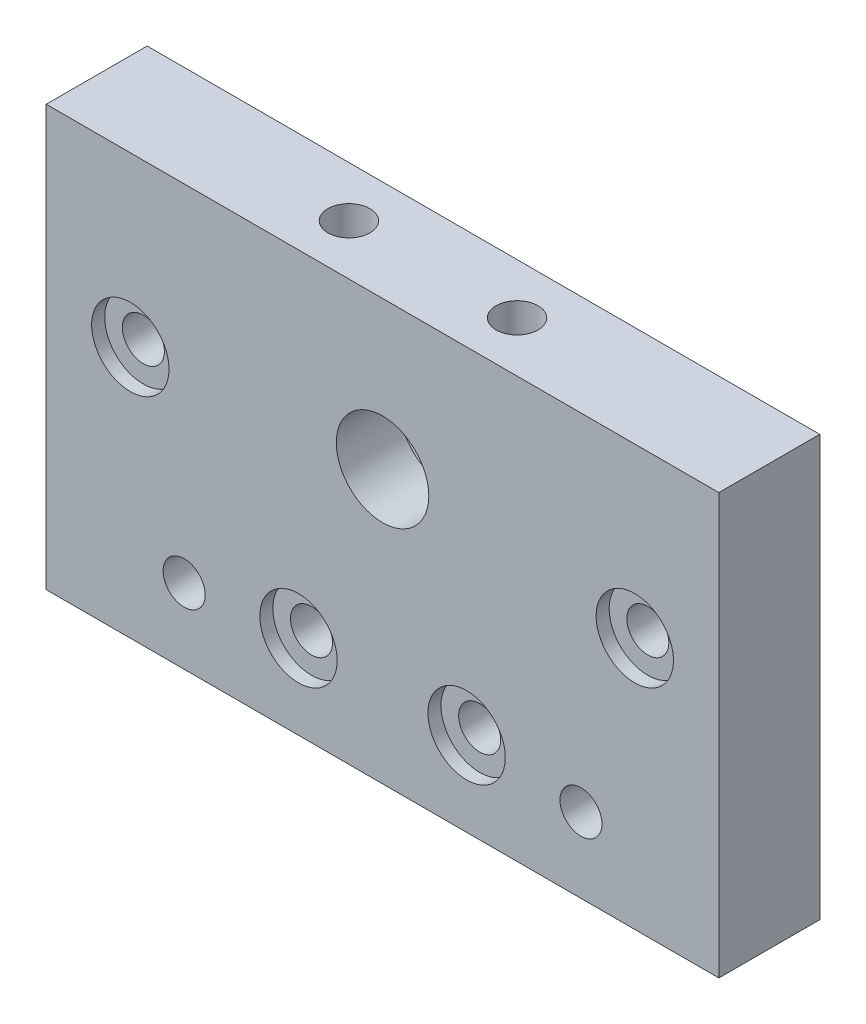
from build123d import *

# Parameters (mm, degrees)
SKETCH1_W           = 80
SKETCH1_H           = 50
SKETCH1_R           = 5.5
SKETCH1_R_2         = 2.5
BOSS_EXTRUDE1_DEPTH = 12
SKETCH2_R           = 4.6
CUT_EXTRUDE1_DEPTH  = 1.55
SKETCH3_R           = 8.05
CUT_EXTRUDE2_DEPTH  = 4.5
SKETCH4_R           = 2.5
CUT_EXTRUDE3_DEPTH  = 11


with BuildPart() as part:
    # Sketch1 → Boss-Extrude1 (new body)
    with BuildSketch(Plane.XY):
        with Locations((40, 25)):
            Rectangle(SKETCH1_W, SKETCH1_H)
        with Locations((40, 32.4)):
            Circle(SKETCH1_R, mode=Mode.SUBTRACT)
        with Locations((10, 30)):
            Circle(SKETCH1_R_2, mode=Mode.SUBTRACT)
        with Locations((70, 30)):
            Circle(SKETCH1_R_2, mode=Mode.SUBTRACT)
        with Locations((30, 10)):
            Circle(SKETCH1_R_2, mode=Mode.SUBTRACT)
        with Locations((50, 10)):
            Circle(SKETCH1_R_2, mode=Mode.SUBTRACT)
        with Locations((16.4, 8.9)):
            Circle(SKETCH1_R_2, mode=Mode.SUBTRACT)
        with Locations((63.6, 8.9)):
            Circle(SKETCH1_R_2, mode=Mode.SUBTRACT)
    extrude(amount=BOSS_EXTRUDE1_DEPTH)

    # Sketch2 → Cut-Extrude1 (cut)
    with BuildSketch(Plane.XY.offset(12)):
        with Locations((10, 30)):
            Circle(SKETCH2_R)
        with Locations((70, 30)):
            Circle(SKETCH2_R)
        with Locations((30, 10)):
            Circle(SKETCH2_R)
        with Locations((50, 10)):
            Circle(SKETCH2_R)
    extrude(amount=-CUT_EXTRUDE1_DEPTH, mode=Mode.SUBTRACT)

    # Sketch3 → Cut-Extrude2 (cut)
    with BuildSketch(Plane(origin=(0, 0, 0), x_dir=(-1, 0, 0), z_dir=(0, 0, -1))):
        with Locations((-40, 32.4)):
            Circle(SKETCH3_R)
    extrude(amount=-CUT_EXTRUDE2_DEPTH, mode=Mode.SUBTRACT)

    # Sketch4 → Cut-Extrude3 (cut)
    with BuildSketch(Plane(origin=(0, 50, 0), x_dir=(1, 0, 0), z_dir=(0, 1, 0))):
        with Locations((50, -6)):
            Circle(SKETCH4_R)
        with Locations((30, -6)):
            Circle(SKETCH4_R)
    extrude(amount=-CUT_EXTRUDE3_DEPTH, mode=Mode.SUBTRACT)


solid = part.part
